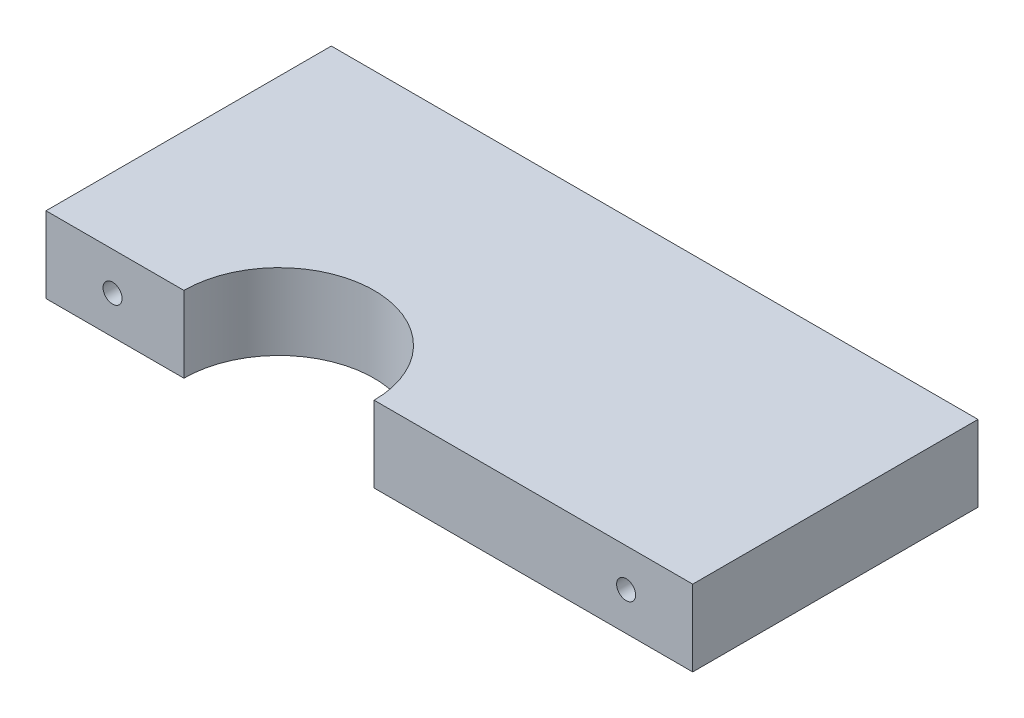
from build123d import *

# Parameters (mm, degrees)
BOSS_EXTRUDE1_DEPTH = 8
CUT_EXTRUDE5_START  = 4
SKETCH2_R           = 1
CUT_EXTRUDE5_DEPTH  = 5
CUT_EXTRUDE6_START  = -27.204301
SKETCH3_R           = 1
CUT_EXTRUDE6_DEPTH  = 10


with BuildPart() as part:
    # Sketch1 → Boss-Extrude1 (new body)
    with BuildSketch(Plane(origin=(0, 0, 0), x_dir=(1, 0, 0), z_dir=(0, 1, 0))):
        with BuildLine():
            Line((-40.967741935, 27.204301075), (27.032258065, 27.204301075))
            Line((27.032258065, 27.204301075), (27.032258065, -2.795698925))
            Line((27.032258065, -2.795698925), (-6.467741935, -2.795698925))
            ThreePointArc((-6.467741935, -2.795698925), (-16.467741935, 7.204301075), (-26.467741935, -2.795698925))
            Line((-26.467741935, -2.795698925), (-40.967741935, -2.795698925))
            Line((-40.967741935, -2.795698925), (-40.967741935, 27.204301075))
        make_face()
    extrude(amount=BOSS_EXTRUDE1_DEPTH)

    # Sketch2 → Cut-Extrude5 (cut)
    with BuildSketch(Plane.XY.offset(CUT_EXTRUDE5_START)):
        with Locations((-33.967741935, 4)):
            Circle(SKETCH2_R)
        with Locations((20.032258065, 4)):
            Circle(SKETCH2_R)
    extrude(amount=-CUT_EXTRUDE5_DEPTH, mode=Mode.SUBTRACT)

    # Sketch3 → Cut-Extrude6 (cut)
    with BuildSketch(Plane.XY.offset(CUT_EXTRUDE6_START)):
        with Locations((17.032258065, 4)):
            Circle(SKETCH3_R)
        with Locations((-30.967741935, 4)):
            Circle(SKETCH3_R)
    extrude(amount=CUT_EXTRUDE6_DEPTH, mode=Mode.SUBTRACT)


solid = part.part
